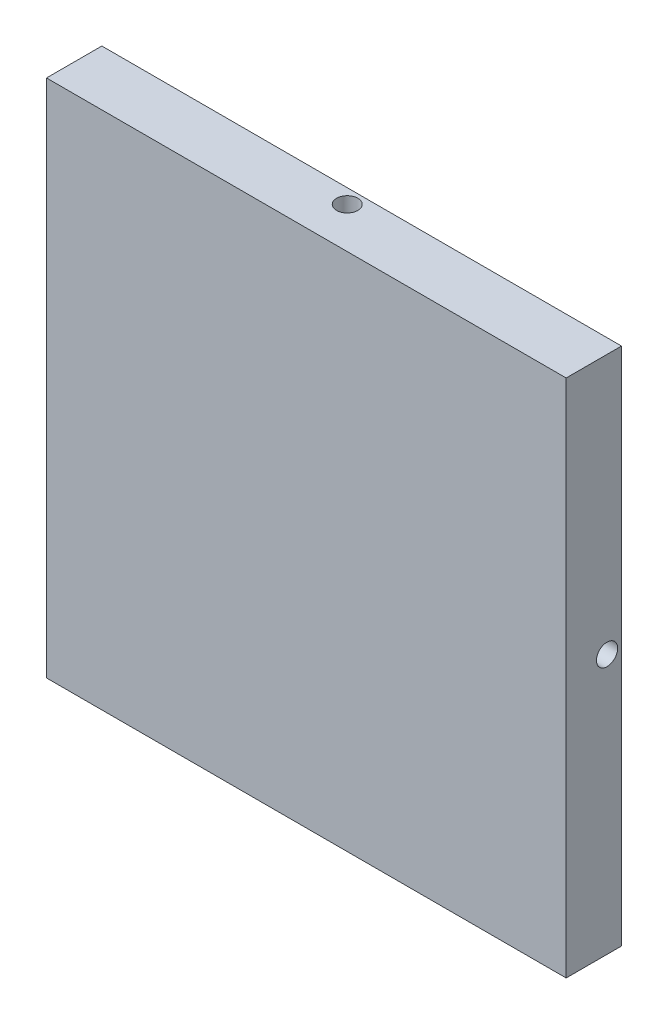
from build123d import *

# Parameters (mm, degrees)
SKETCH1_W                = 171.45
SKETCH1_H                = 171.45
SKETCH1_R                = 1.54305
BOSS_EXTRUDE1_DEPTH      = 8.73125
SKETCH1_3_W              = 171.45
SKETCH1_3_H              = 171.45
SKETCH1_3_R              = 3.175
SKETCH1_3_R_2            = 76.99375
SKETCH1_3_R_3            = 3.3
BOSS_EXTRUDE2_DEPTH      = 9.525
SKETCH1_4_R              = 3.3
BOSS_EXTRUDE3_DEPTH      = 18.3515
CUT_EXTRUDE1_START       = -8.810843
SKETCH2_R                = 3.5
CUT_EXTRUDE1_DEPTH       = 8.810843
CIRPATTERN1_COUNT        = 4
SKETCH1_5_R              = 1.54305
BOSS_EXTRUDE4_DEPTH      = 8.73125
BOSS_EXTRUDE4_DEPTH_BACK = 9.525


with BuildPart() as part:
    # Sketch1 → Boss-Extrude1 (new body)
    with BuildSketch(Plane.XY):
        Rectangle(SKETCH1_W, SKETCH1_H)
        with Locations((0, 25.4)):
            Circle(SKETCH1_R, mode=Mode.SUBTRACT)
    extrude(amount=BOSS_EXTRUDE1_DEPTH)

    # Sketch1_3 → Boss-Extrude2 (add)
    with BuildSketch(Plane.XY):
        Rectangle(SKETCH1_3_W, SKETCH1_3_H)
        with Locations((-73.025, -73.025)):
            Circle(SKETCH1_3_R, mode=Mode.SUBTRACT)
        with Locations((73.025, -73.025)):
            Circle(SKETCH1_3_R, mode=Mode.SUBTRACT)
        with Locations((73.025, 73.025)):
            Circle(SKETCH1_3_R, mode=Mode.SUBTRACT)
        with Locations((-73.025, 73.025)):
            Circle(SKETCH1_3_R, mode=Mode.SUBTRACT)
        Circle(SKETCH1_3_R_2, mode=Mode.SUBTRACT)
        Circle(SKETCH1_3_R_3)
    extrude(amount=-BOSS_EXTRUDE2_DEPTH)

    # Sketch1_4 → Boss-Extrude3 (add)
    with BuildSketch(Plane.XY):
        Circle(SKETCH1_4_R)
    extrude(amount=-BOSS_EXTRUDE3_DEPTH)

    # Sketch2 → Cut-Extrude1 (cut)
    with BuildSketch(Plane(origin=(0, 85.725, 0), x_dir=(1, 0, 0), z_dir=(0, 1, 0)).offset(CUT_EXTRUDE1_START)):
        with Locations((0, 4.7625)):
            Circle(SKETCH2_R)
    cut_extrude1 = extrude(amount=CUT_EXTRUDE1_DEPTH, mode=Mode.SUBTRACT)

    # CirPattern1: Cut-Extrude1 ×4 about axis
    cirpattern1_axis = Axis((0, 0, -9.525), (0, 0, 1))
    for i in range(1, CIRPATTERN1_COUNT):
        add(cut_extrude1.rotate(cirpattern1_axis, i * 360 / CIRPATTERN1_COUNT), mode=Mode.SUBTRACT)

    # Sketch1_5 → Boss-Extrude4 (add, two sides)
    with BuildSketch(Plane.XY) as boss_extrude4_sk:
        with Locations((0, 25.4)):
            Circle(SKETCH1_5_R)
    extrude(amount=BOSS_EXTRUDE4_DEPTH)
    extrude(boss_extrude4_sk.sketch, amount=-BOSS_EXTRUDE4_DEPTH_BACK)


solid = part.part
